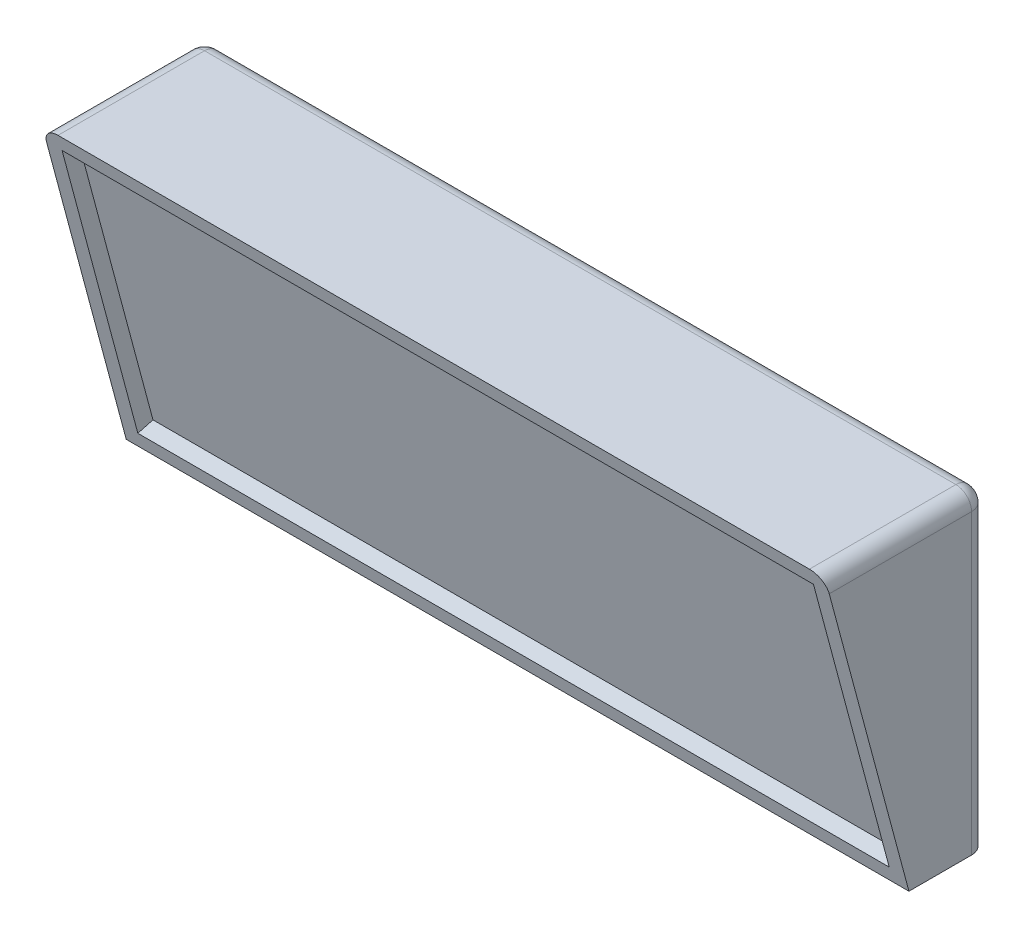
from build123d import *

# Parameters (mm, degrees)
BOSS_EXTRUDE1_DEPTH = 63.5
SKETCH2_W           = 121.92
SKETCH2_H           = 47.512029965
CUT_EXTRUDE1_DEPTH  = 2.54
FILLET1_R           = 2.54


with BuildPart() as part:
    # Sketch1 → Boss-Extrude1 (new body, symmetric)
    with BuildSketch(Plane(origin=(0, 0, 0), x_dir=(0, 0, -1), z_dir=(1, 0, 0))):
        Polygon((0, 0), (0, 50.8), (-26.311818976, 50.8), (-12.7, 0), align=None)
    extrude(amount=BOSS_EXTRUDE1_DEPTH, both=True)

    # Sketch2 → Cut-Extrude1 (cut)
    with BuildSketch(Plane(origin=(0, -3.175, 11.849261314), x_dir=(1, 0, 0), z_dir=(0, -0.258819045, 0.965925826))):
        with Locations((0, 29.583016856)):
            Rectangle(SKETCH2_W, SKETCH2_H)
    extrude(amount=-CUT_EXTRUDE1_DEPTH, mode=Mode.SUBTRACT)

    # Fillet1
    fillet1_edges = [part.edges().sort_by_distance(p)[0] for p in [
        (63.5, 50.8, 13.155909488),
        (-63.5, 50.8, 13.155909488),
        (-63.5, 25.4, 0),
        (0, 50.8, 0),
        (63.5, 25.4, 0),
    ]]
    fillet(fillet1_edges, radius=FILLET1_R)


solid = part.part
